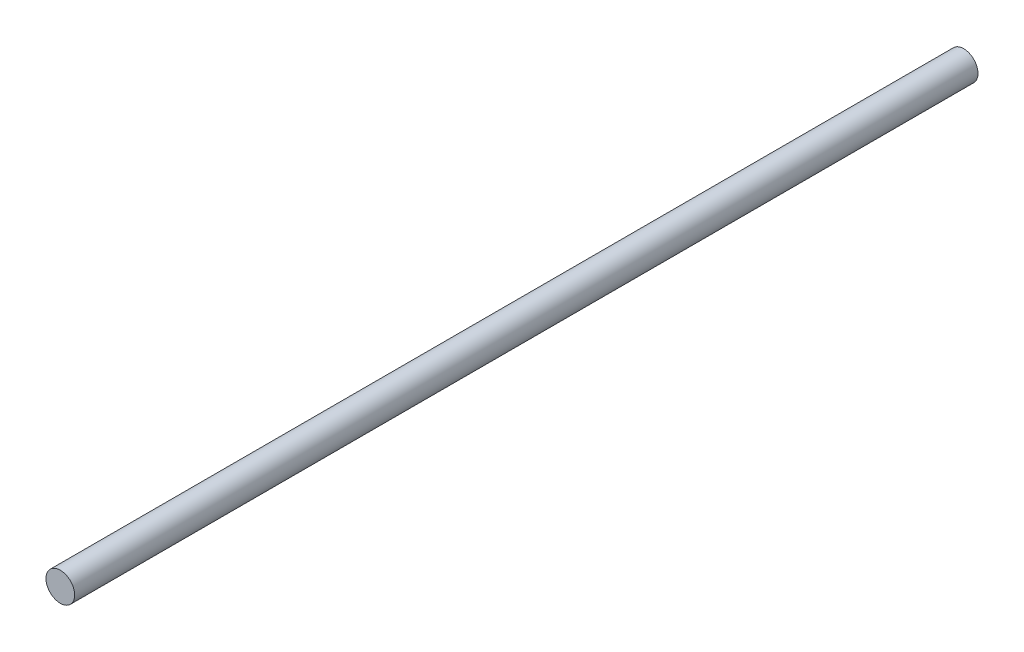
from build123d import *

# Parameters (mm, degrees)
SKETCH1_R           = 1.5875
BOSS_EXTRUDE1_DEPTH = 100


with BuildPart() as part:
    # Sketch1 → Boss-Extrude1 (new body)
    with BuildSketch(Plane.XY):
        Circle(SKETCH1_R)
    extrude(amount=BOSS_EXTRUDE1_DEPTH)


solid = part.part
